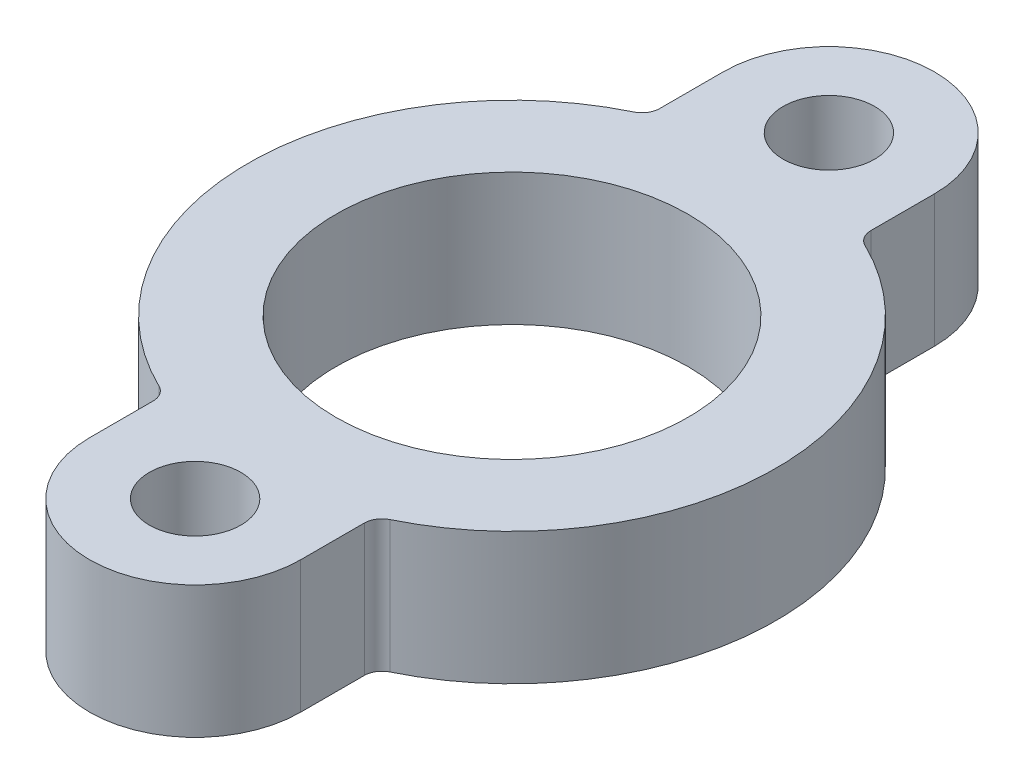
from build123d import *

# Parameters (mm, degrees)
SKETCH1_R           = 12.7
SKETCH1_R_2         = 3.302
BOSS_EXTRUDE1_DEPTH = 9.525


with BuildPart() as part:
    # Sketch1 → Boss-Extrude1 (new body)
    with BuildSketch(Plane(origin=(0, 0, 0), x_dir=(1, 0, 0), z_dir=(0, 1, 0))):
        with BuildLine():
            Line((7.62, 22.86), (7.62, 18.272118104))
            ThreePointArc((7.62, 18.272118104), (7.813305115, 17.598598895), (8.334375, 17.130110722))
            ThreePointArc((8.334375, 17.130110722), (19.05, 0), (8.334375, -17.130110722))
            ThreePointArc((8.334375, -17.130110722), (7.813305115, -17.598598895), (7.62, -18.272118104))
            Line((7.62, -18.272118104), (7.62, -22.86))
            ThreePointArc((7.62, -22.86), (0, -30.48), (-7.62, -22.86))
            Line((-7.62, -22.86), (-7.62, -18.272118104))
            ThreePointArc((-7.62, -18.272118104), (-7.813305115, -17.598598895), (-8.334375, -17.130110722))
            ThreePointArc((-8.334375, -17.130110722), (-19.05, 0), (-8.334375, 17.130110722))
            ThreePointArc((-8.334375, 17.130110722), (-7.813305115, 17.598598895), (-7.62, 18.272118104))
            Line((-7.62, 18.272118104), (-7.62, 22.86))
            ThreePointArc((-7.62, 22.86), (0, 30.48), (7.62, 22.86))
        make_face()
        Circle(SKETCH1_R, mode=Mode.SUBTRACT)
        with Locations((0, 22.86)):
            Circle(SKETCH1_R_2, mode=Mode.SUBTRACT)
        with Locations((0, -22.86)):
            Circle(SKETCH1_R_2, mode=Mode.SUBTRACT)
    extrude(amount=BOSS_EXTRUDE1_DEPTH)


solid = part.part
